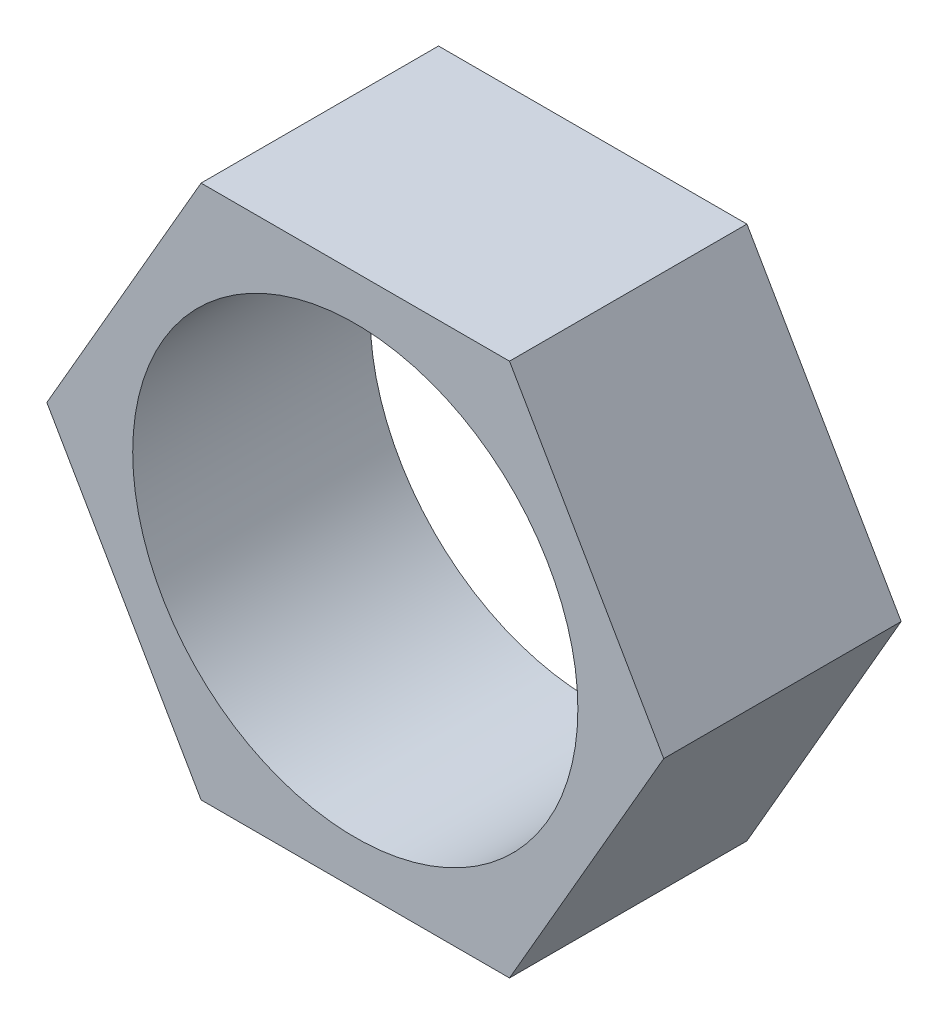
from build123d import *

# Parameters (mm, degrees)
Y_KSEKLIK_EKSTR_ZYON1_DEPTH = 80
IZIM3_R                     = 75
KES_EKSTR_ZYON1_DEPTH       = 134


with BuildPart() as part:
    # Çizim1 → Yükseklik-Ekstrüzyon1 (new body)
    with BuildSketch(Plane.XY):
        Polygon((103.923048454, 0), (51.961524227, 90), (-51.961524227, 90), (-103.923048454, 0), (-51.961524227, -90), (51.961524227, -90), align=None)
    extrude(amount=Y_KSEKLIK_EKSTR_ZYON1_DEPTH)

    # Çizim3 → Kes-Ekstrüzyon1 (cut)
    with BuildSketch(Plane(origin=(0, 0, 0), x_dir=(-1, 0, 0), z_dir=(0, 0, -1))):
        Circle(IZIM3_R)
    extrude(amount=-KES_EKSTR_ZYON1_DEPTH, mode=Mode.SUBTRACT)


solid = part.part
